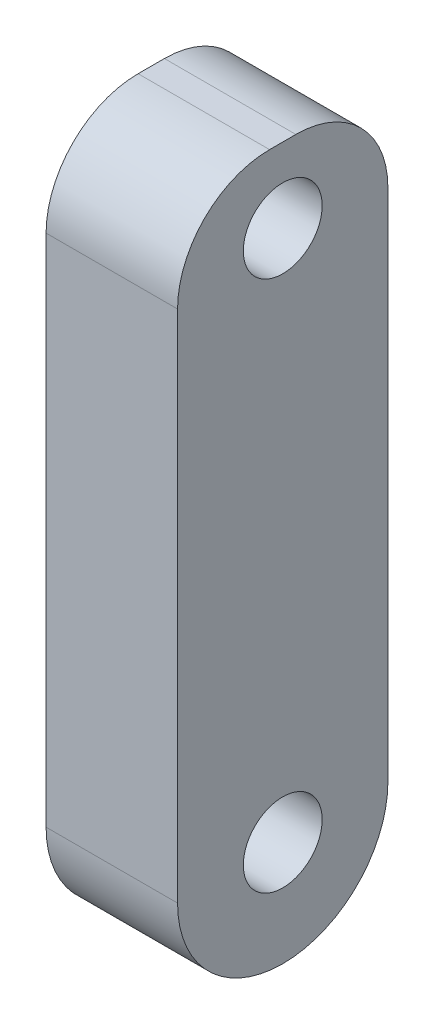
from build123d import *

# Parameters (mm, degrees)
SKETCH1_R           = 1.5
BOSS_EXTRUDE1_DEPTH = 5


with BuildPart() as part:
    # Sketch1 → Boss-Extrude1 (new body)
    with BuildSketch(Plane(origin=(0, 0, 0), x_dir=(0, 0, -1), z_dir=(1, 0, 0))):
        with BuildLine():
            Line((44.162641246, 29.392068372), (44.162641246, 9.826128546))
            ThreePointArc((44.162641246, 9.826128546), (48.162641246, 5.826128546), (52.162641246, 9.826128546))
            Line((52.162641246, 9.826128546), (52.162641246, 29.392068372))
            ThreePointArc((52.162641246, 29.392068372), (51.137514981, 31.866942106), (48.662641246, 32.892068372))
            Line((48.662641246, 32.892068372), (47.662641246, 32.892068372))
            ThreePointArc((47.662641246, 32.892068372), (45.187767512, 31.866942106), (44.162641246, 29.392068372))
        make_face()
        with Locations((48.162641246, 30.051539634)):
            Circle(SKETCH1_R, mode=Mode.SUBTRACT)
        with Locations((48.162641246, 9.826128546)):
            Circle(SKETCH1_R, mode=Mode.SUBTRACT)
    extrude(amount=BOSS_EXTRUDE1_DEPTH)


solid = part.part
